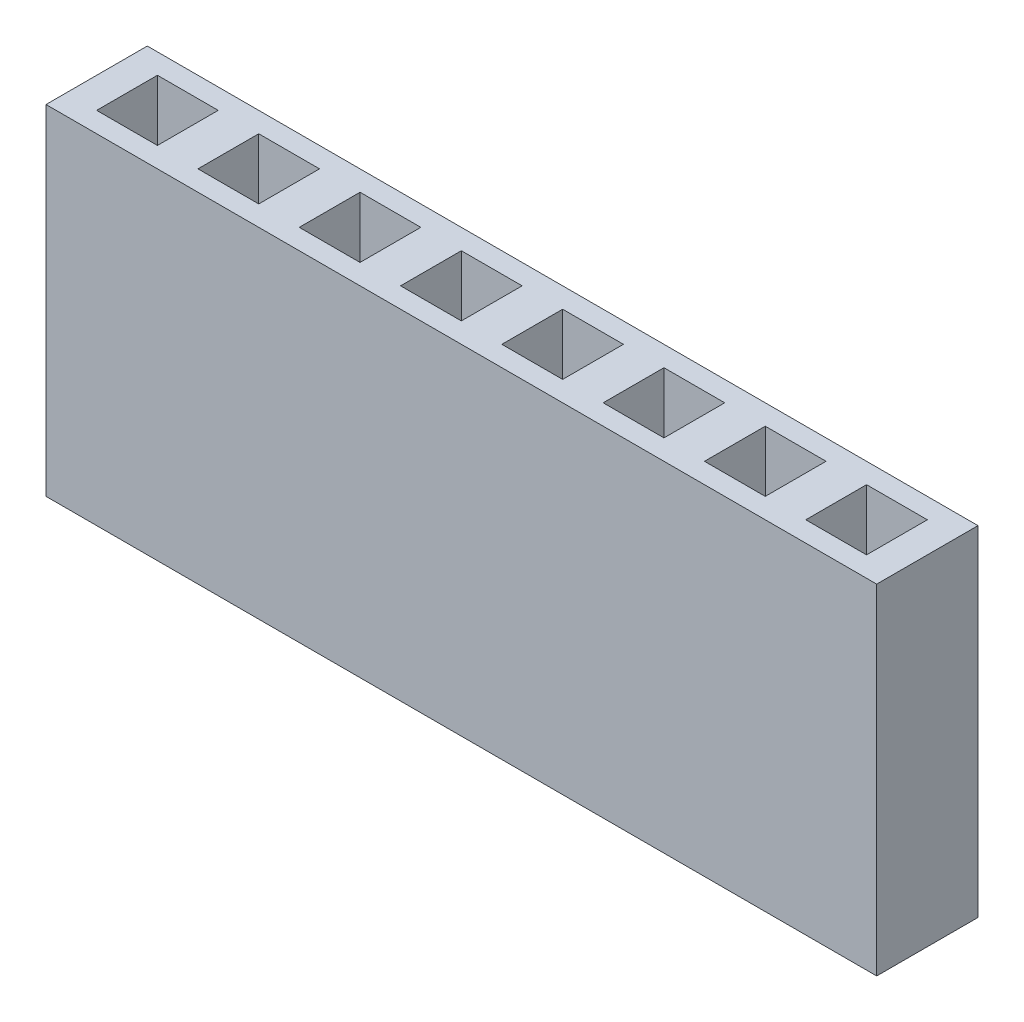
from build123d import *

# Parameters (mm, degrees)
SKETCH1_W           = 20.828
SKETCH1_H           = 2.54
BOSS_EXTRUDE1_DEPTH = 8.509
SKETCH2_W           = 1.524
SKETCH2_H           = 1.524
CUT_EXTRUDE1_DEPTH  = 5.9944


with BuildPart() as part:
    # Sketch1 → Boss-Extrude1 (new body)
    with BuildSketch(Plane(origin=(0, 0, 0), x_dir=(1, 0, 0), z_dir=(0, 1, 0))):
        Rectangle(SKETCH1_W, SKETCH1_H)
    extrude(amount=BOSS_EXTRUDE1_DEPTH)

    # Sketch2 → Cut-Extrude1 (cut)
    with BuildSketch(Plane(origin=(0, 8.509, 0), x_dir=(1, 0, 0), z_dir=(0, 1, 0))):
        with Locations((-1.27, 0)):
            Rectangle(SKETCH2_W, SKETCH2_H)
        with Locations((-3.81, 0)):
            Rectangle(SKETCH2_W, SKETCH2_H)
        with Locations((-6.35, 0)):
            Rectangle(SKETCH2_W, SKETCH2_H)
        with Locations((-8.89, 0)):
            Rectangle(SKETCH2_W, SKETCH2_H)
        with Locations((1.27, 0)):
            Rectangle(SKETCH2_W, SKETCH2_H)
        with Locations((3.81, 0)):
            Rectangle(SKETCH2_W, SKETCH2_H)
        with Locations((6.35, 0)):
            Rectangle(SKETCH2_W, SKETCH2_H)
        with Locations((8.89, 0)):
            Rectangle(SKETCH2_W, SKETCH2_H)
    extrude(amount=-CUT_EXTRUDE1_DEPTH, mode=Mode.SUBTRACT)


solid = part.part
